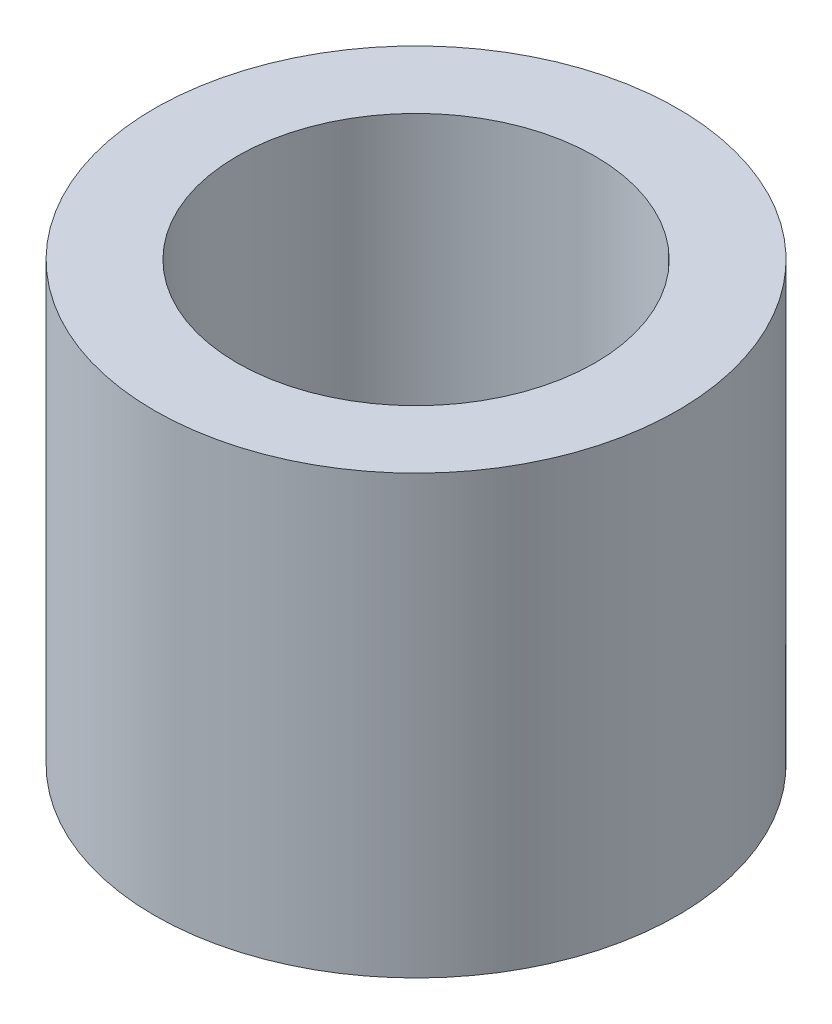
from build123d import *

# Parameters (mm, degrees)
SKETCH1_R           = 3.8
SKETCH1_R_2         = 2.6
BOSS_EXTRUDE1_DEPTH = 6.35


with BuildPart() as part:
    # Sketch1 → Boss-Extrude1 (new body)
    with BuildSketch(Plane(origin=(0, 0, 0), x_dir=(1, 0, 0), z_dir=(0, 1, 0))):
        Circle(SKETCH1_R)
        Circle(SKETCH1_R_2, mode=Mode.SUBTRACT)
    extrude(amount=BOSS_EXTRUDE1_DEPTH)


solid = part.part
